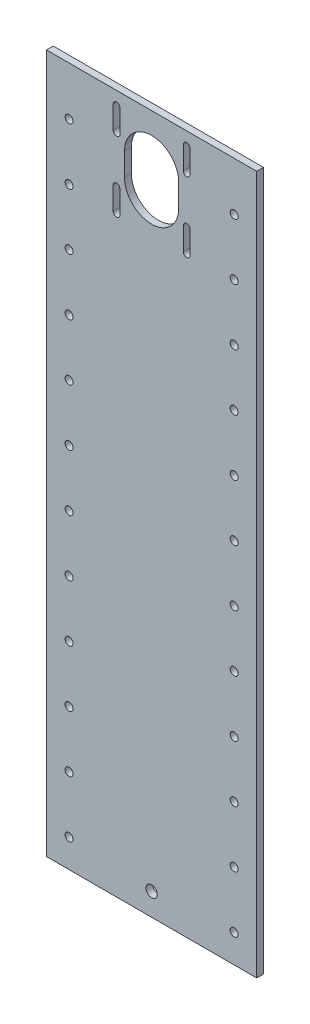
from build123d import *

# Parameters (mm, degrees)
ESQUISSE1_W             = 93
ESQUISSE1_H             = 309
BOSS_EXTRU_1_DEPTH      = 3
PERSAGE_STEPPER_DEPTH   = 4
ESQUISSE3_R             = 2.5
ENL_V_MAT_EXTRU_1_DEPTH = 3
ESQUISSE4_R             = 1.75
ENL_V_MAT_EXTRU_2_DEPTH = 3


with BuildPart() as part:
    # Esquisse1 → Boss.-Extru.1 (new body)
    with BuildSketch(Plane.XY):
        with Locations((46.5, 154.5)):
            Rectangle(ESQUISSE1_W, ESQUISSE1_H)
    extrude(amount=BOSS_EXTRU_1_DEPTH)

    # Esquisse2 → Persage Stepper (cut, through all)
    with BuildSketch(Plane.XY.offset(3)):
        with BuildLine():
            Line((34.5, 277.5), (34.5, 287.5))
            ThreePointArc((34.5, 287.5), (46.5, 299.5), (58.5, 287.5))
            Line((58.5, 287.5), (58.5, 277.5))
            ThreePointArc((58.5, 277.5), (46.5, 265.5), (34.5, 277.5))
        make_face()
        with BuildLine():
            Line((29.5, 293), (29.5, 303))
            ThreePointArc((29.5, 303), (31, 304.5), (32.5, 303))
            Line((32.5, 303), (32.5, 293))
            ThreePointArc((32.5, 293), (31, 291.5), (29.5, 293))
        make_face()
        with BuildLine():
            Line((60.5, 293), (60.5, 303))
            ThreePointArc((60.5, 303), (62, 304.5), (63.5, 303))
            Line((63.5, 303), (63.5, 293))
            ThreePointArc((63.5, 293), (62, 291.5), (60.5, 293))
        make_face()
        with BuildLine():
            Line((60.5, 262), (60.5, 272))
            ThreePointArc((60.5, 272), (62, 273.5), (63.5, 272))
            Line((63.5, 272), (63.5, 262))
            ThreePointArc((63.5, 262), (62, 260.5), (60.5, 262))
        make_face()
        with BuildLine():
            Line((29.5, 262), (29.5, 272))
            ThreePointArc((29.5, 272), (31, 273.5), (32.5, 272))
            Line((32.5, 272), (32.5, 262))
            ThreePointArc((32.5, 262), (31, 260.5), (29.5, 262))
        make_face()
    extrude(amount=-PERSAGE_STEPPER_DEPTH, mode=Mode.SUBTRACT)

    # Esquisse3 → Enlèv. mat.-Extru.1 (cut)
    with BuildSketch(Plane.XY.offset(3)):
        with Locations((46.5, 10)):
            Circle(ESQUISSE3_R)
    extrude(amount=-ENL_V_MAT_EXTRU_1_DEPTH, mode=Mode.SUBTRACT)

    # Esquisse4 → Enlèv. mat.-Extru.2 (cut)
    with BuildSketch(Plane.XY.offset(3)):
        with Locations((10, 12.5)):
            Circle(ESQUISSE4_R)
        with Locations((83, 12.5)):
            Circle(ESQUISSE4_R)
        with Locations((10, 37.5)):
            Circle(ESQUISSE4_R)
        with Locations((83, 37.5)):
            Circle(ESQUISSE4_R)
        with Locations((10, 62.5)):
            Circle(ESQUISSE4_R)
        with Locations((83, 62.5)):
            Circle(ESQUISSE4_R)
        with Locations((10, 87.5)):
            Circle(ESQUISSE4_R)
        with Locations((83, 87.5)):
            Circle(ESQUISSE4_R)
        with Locations((10, 112.5)):
            Circle(ESQUISSE4_R)
        with Locations((83, 112.5)):
            Circle(ESQUISSE4_R)
        with Locations((10, 137.5)):
            Circle(ESQUISSE4_R)
        with Locations((83, 137.5)):
            Circle(ESQUISSE4_R)
        with Locations((10, 162.5)):
            Circle(ESQUISSE4_R)
        with Locations((83, 162.5)):
            Circle(ESQUISSE4_R)
        with Locations((10, 187.5)):
            Circle(ESQUISSE4_R)
        with Locations((83, 187.5)):
            Circle(ESQUISSE4_R)
        with Locations((10, 212.5)):
            Circle(ESQUISSE4_R)
        with Locations((83, 212.5)):
            Circle(ESQUISSE4_R)
        with Locations((10, 237.5)):
            Circle(ESQUISSE4_R)
        with Locations((83, 237.5)):
            Circle(ESQUISSE4_R)
        with Locations((10, 262.5)):
            Circle(ESQUISSE4_R)
        with Locations((83, 262.5)):
            Circle(ESQUISSE4_R)
        with Locations((10, 287.5)):
            Circle(ESQUISSE4_R)
        with Locations((83, 287.5)):
            Circle(ESQUISSE4_R)
    extrude(amount=-ENL_V_MAT_EXTRU_2_DEPTH, mode=Mode.SUBTRACT)


solid = part.part
